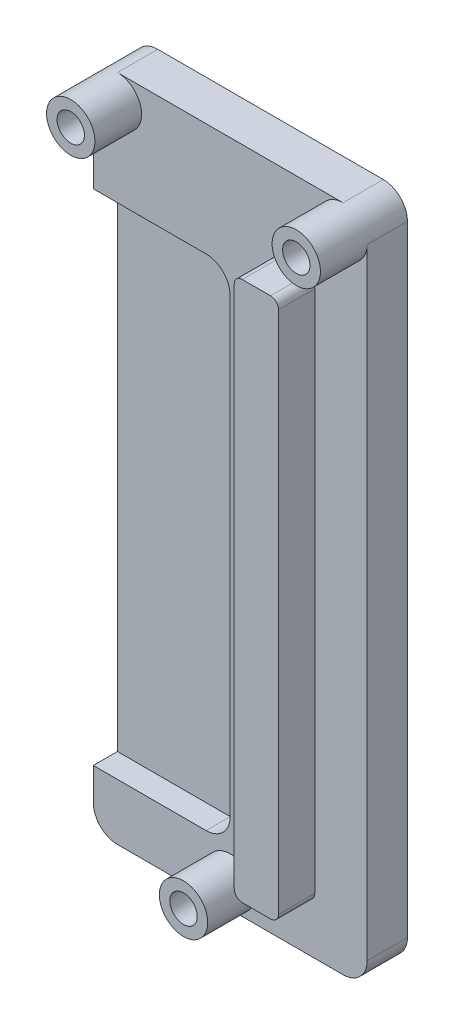
from build123d import *

# Parameters (mm, degrees)
BOSS_EXTRU_2_DEPTH      = 5
ESQUISSE4_R             = 3
BOSS_EXTRU_3_DEPTH      = 5.8
D_GAGEMENT_M31_D        = 3.4
BOSS_EXTRU_4_DEPTH      = 4.5
ENL_V_MAT_EXTRU_1_DEPTH = 3


with BuildPart() as part:
    # Esquisse1 → Boss.-Extru.2 (new body)
    with BuildSketch(Plane.XY):
        with BuildLine():
            Line((3, 0), (31, 0))
            ThreePointArc((31, 0), (33.121320344, 0.878679656), (34, 3))
            Line((34, 3), (34, 80))
            ThreePointArc((34, 80), (33.121320344, 82.121320344), (31, 83))
            Line((31, 83), (3, 83))
            ThreePointArc((3, 83), (0.878679656, 82.121320344), (0, 80))
            Line((0, 80), (0, 3))
            ThreePointArc((0, 3), (0.878679656, 0.878679656), (3, 0))
        make_face()
    extrude(amount=BOSS_EXTRU_2_DEPTH)

    # Esquisse4 → Boss.-Extru.3 (add)
    with BuildSketch(Plane.XY.offset(5)):
        with Locations((3, 80)):
            Circle(ESQUISSE4_R)
        with Locations((31, 80)):
            Circle(ESQUISSE4_R)
        with Locations((17, 3)):
            Circle(ESQUISSE4_R)
    extrude(amount=BOSS_EXTRU_3_DEPTH)

    # Dégagement M31 (through all)
    with Locations(Plane.XY.offset(10.8)):
        with Locations((3, 80), (31, 80), (17, 3)):
            Hole(D_GAGEMENT_M31_D / 2)

    # Esquisse2 → Boss.-Extru.4 (add)
    with BuildSketch(Plane.XY.offset(5)):
        with BuildLine():
            Line((23, 73), (26.5, 73))
            ThreePointArc((26.5, 73), (27.207106781, 72.707106781), (27.5, 72))
            Line((27.5, 72), (27.5, 7))
            ThreePointArc((27.5, 7), (27.207106781, 6.292893219), (26.5, 6))
            Line((26.5, 6), (23, 6))
            ThreePointArc((23, 6), (22.292893219, 6.292893219), (22, 7))
            Line((22, 7), (22, 72))
            ThreePointArc((22, 72), (22.292893219, 72.707106781), (23, 73))
        make_face()
    extrude(amount=BOSS_EXTRU_4_DEPTH)

    # Esquisse7 → Enlèv. mat.-Extru.1 (cut)
    with BuildSketch(Plane.XY.offset(5)):
        with BuildLine():
            Line((14, 69), (0, 69))
            Line((0, 69), (0, 7))
            Line((0, 7), (14, 7))
            ThreePointArc((14, 7), (16.121320344, 7.878679656), (17, 10))
            Line((17, 10), (17, 66))
            ThreePointArc((17, 66), (16.121320344, 68.121320344), (14, 69))
        make_face()
    extrude(amount=-ENL_V_MAT_EXTRU_1_DEPTH, mode=Mode.SUBTRACT)


solid = part.part
